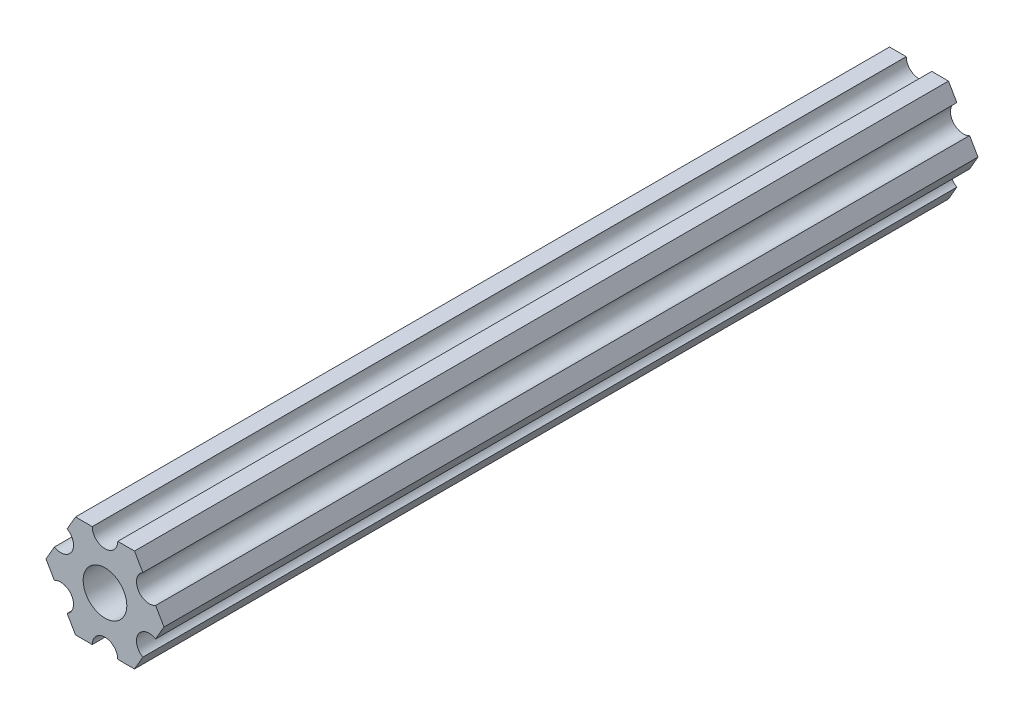
from build123d import *

# Parameters (mm, degrees)
SKETCH1_R               = 1.5875
BOSS_EXTRUDE1_DEPTH     = 95.25
F_1_4_20_TAPPED_HOLE2_D = 5.1054


with BuildPart() as part:
    # Sketch1 → Boss-Extrude1 (new body)
    with BuildSketch(Plane.XY):
        with BuildLine():
            Line((-4.430514159, -4.283916762), (-3.451917569, -5.978896013))
            Line((-3.451917569, -5.978896013), (-1.49472801, -5.978896013))
            ThreePointArc((-1.49472801, -5.978896013), (-3.62e-07, -4.484168365), (1.49472801, -5.978896013))
            Line((1.49472801, -5.978896013), (3.451916913, -5.978896013))
            Line((3.451916913, -5.978896013), (4.430513537, -4.28391694))
            ThreePointArc((4.430513537, -4.28391694), (3.883406572, -2.242085948), (5.925237563, -1.694978983))
            Line((5.925237563, -1.694978983), (6.903834188, 9.1e-08))
            Line((6.903834188, 9.1e-08), (5.925237797, 1.694979115))
            ThreePointArc((5.925237797, 1.694979115), (3.883406856, 2.242086266), (4.430514007, 4.283917207))
            Line((4.430514007, 4.283917207), (3.451917569, 5.978896313))
            Line((3.451917569, 5.978896313), (1.494720042, 5.978896313))
            ThreePointArc((1.494720042, 5.978896313), (3.62e-07, 4.484176634), (-1.494720042, 5.978896313))
            Line((-1.494720042, 5.978896313), (-3.451916913, 5.978896313))
            Line((-3.451916913, 5.978896313), (-4.43051364, 4.283917299))
            ThreePointArc((-4.43051364, 4.283917299), (-3.883406799, 2.242086274), (-5.925237823, 1.694979433))
            Line((-5.925237823, 1.694979433), (-6.90383455, 4.18e-07))
            Line((-6.90383455, 4.18e-07), (-5.925238028, -1.694978715))
            ThreePointArc((-5.925238028, -1.694978715), (-3.88340707, -2.242085804), (-4.430514159, -4.283916762))
        make_face()
        Circle(SKETCH1_R, mode=Mode.SUBTRACT)
    extrude(amount=-BOSS_EXTRUDE1_DEPTH)

    # 1/4-20 Tapped Hole2 (through all)
    with Locations(Plane.XY):
        with Locations((0, 0)):
            Hole(F_1_4_20_TAPPED_HOLE2_D / 2)


solid = part.part
